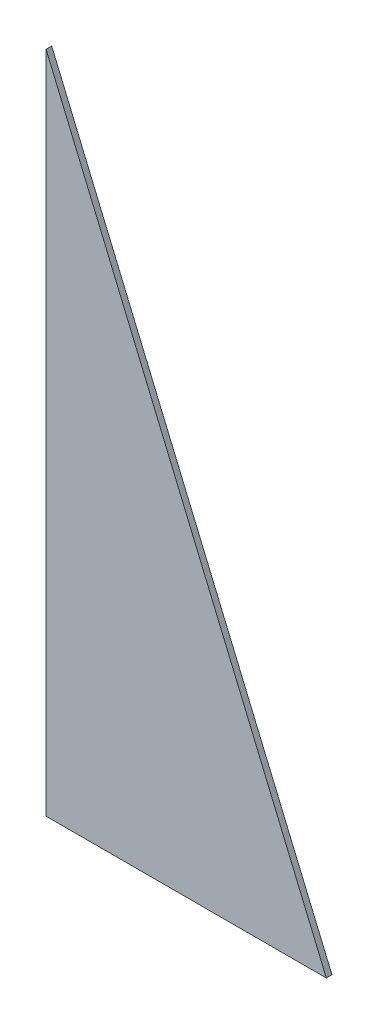
from build123d import *

# Parameters (mm, degrees)
SKETCH1_W           = 100
SKETCH1_H           = 237
BOSS_EXTRUDE1_DEPTH = 2
CUT_EXTRUDE1_DEPTH  = 3


with BuildPart() as part:
    # Sketch1 → Boss-Extrude1 (new body)
    with BuildSketch(Plane.XY):
        Rectangle(SKETCH1_W, SKETCH1_H)
    extrude(amount=BOSS_EXTRUDE1_DEPTH)

    # Sketch2 → Cut-Extrude1 (cut, through all)
    with BuildSketch(Plane.XY.offset(2)):
        Polygon((-50, 118.5), (50, -118.5), (87.001497682, 120.954679305), align=None)
    extrude(amount=-CUT_EXTRUDE1_DEPTH, mode=Mode.SUBTRACT)


solid = part.part
